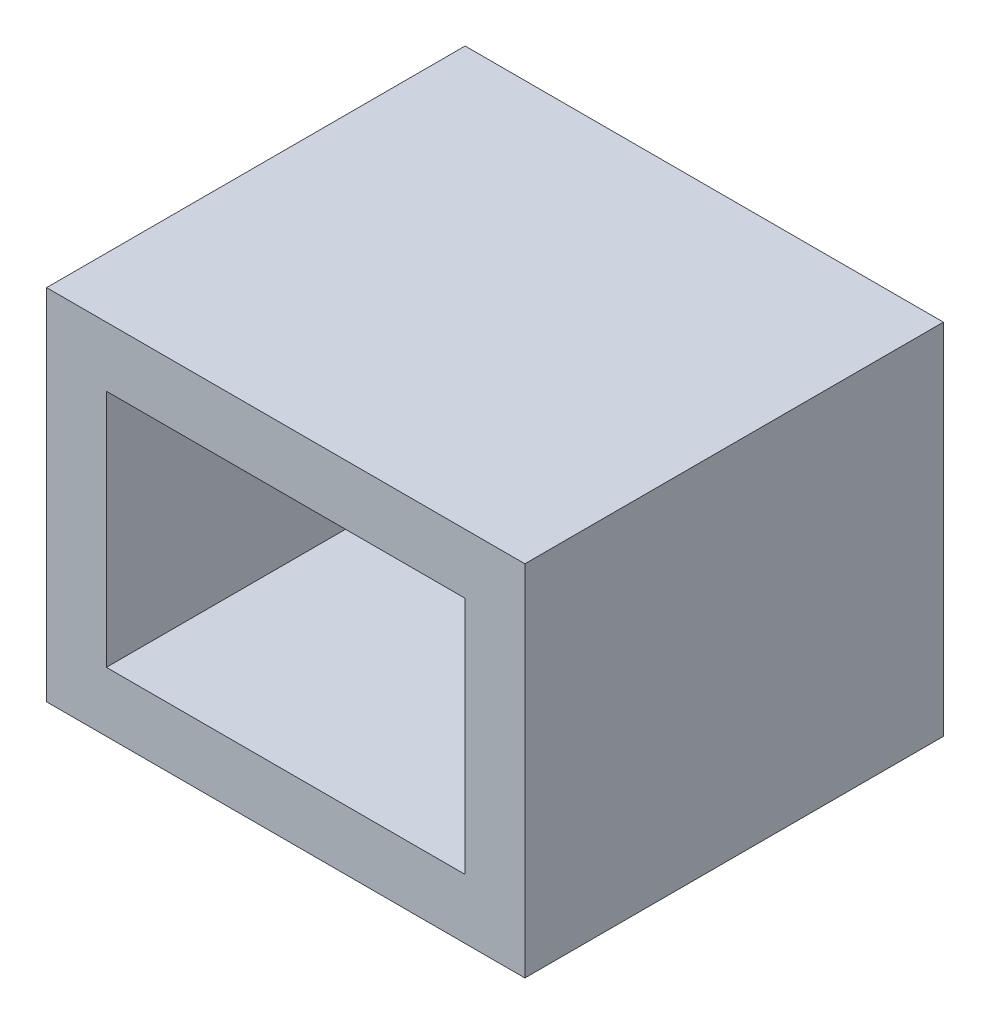
from build123d import *

# Parameters (mm, degrees)
CROQUIS1_W              = 8
CROQUIS1_H              = 6
CROQUIS1_W_2            = 6
CROQUIS1_H_2            = 4
SALIENTE_EXTRUIR1_DEPTH = 6
CROQUIS3_W              = 8
CROQUIS3_H              = 6
SALIENTE_EXTRUIR2_DEPTH = 1


with BuildPart() as part:
    # Croquis1 → Saliente-Extruir1 (new body)
    with BuildSketch(Plane.XY):
        with Locations((-24.435275528, 4.888284157)):
            Rectangle(CROQUIS1_W, CROQUIS1_H)
        with Locations((-24.435275528, 4.888284157)):
            Rectangle(CROQUIS1_W_2, CROQUIS1_H_2, mode=Mode.SUBTRACT)
    extrude(amount=SALIENTE_EXTRUIR1_DEPTH)

    # Croquis3 → Saliente-Extruir2 (add)
    with BuildSketch(Plane(origin=(0, 0, 0), x_dir=(-1, 0, 0), z_dir=(0, 0, -1))):
        with Locations((24.435275528, 4.888284157)):
            Rectangle(CROQUIS3_W, CROQUIS3_H)
    extrude(amount=SALIENTE_EXTRUIR2_DEPTH)


solid = part.part
